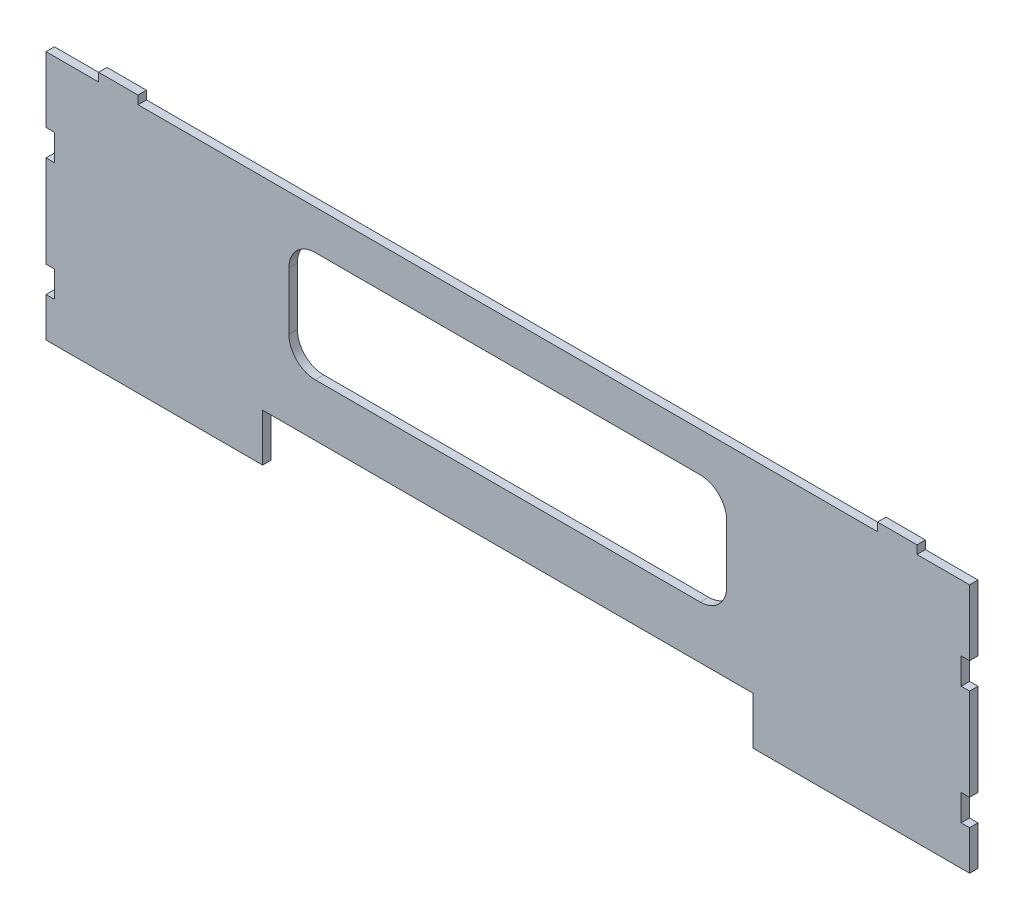
from build123d import *

# Parameters (mm, degrees)
BOSS_EXTRUDE1_DEPTH = 4.064
SKETCH2_W           = 4.064
SKETCH2_H           = 12.7
CUT_EXTRUDE1_DEPTH  = 5.064
CUT_EXTRUDE2_DEPTH  = 5.064


with BuildPart() as part:
    # Sketch1 → Boss-Extrude1 (new body)
    with BuildSketch(Plane.XY):
        Polygon((-118.4275, -120.65), (-118.4275, -97.663), (118.4275, -97.663), (118.4275, -120.65), (223.0755, -120.65), (223.0755, 0), (197.6755, 0), (197.6755, 4.064), (178.6255, 4.064), (178.6255, 0), (-178.6255, 0), (-178.6255, 4.064), (-197.6755, 4.064), (-197.6755, 0), (-223.0755, 0), (-223.0755, -120.65), align=None)
    extrude(amount=BOSS_EXTRUDE1_DEPTH)

    # Sketch2 → Cut-Extrude1 (cut, through all)
    with BuildSketch(Plane.XY.offset(4.064)):
        with Locations((-221.0435, -38.1)):
            Rectangle(SKETCH2_W, SKETCH2_H)
        with Locations((-221.0435, -95.25)):
            Rectangle(SKETCH2_W, SKETCH2_H)
        with Locations((221.0435, -95.25)):
            Rectangle(SKETCH2_W, SKETCH2_H)
        with Locations((221.0435, -38.1)):
            Rectangle(SKETCH2_W, SKETCH2_H)
    extrude(amount=-CUT_EXTRUDE1_DEPTH, mode=Mode.SUBTRACT)

    # Sketch3 → Cut-Extrude2 (cut, through all)
    with BuildSketch(Plane.XY.offset(4.064)):
        with BuildLine():
            Line((-93.0275, -19.05), (93.0275, -19.05))
            ThreePointArc((93.0275, -19.05), (102.007756121, -22.769743879), (105.7275, -31.75))
            Line((105.7275, -31.75), (105.7275, -59.563))
            ThreePointArc((105.7275, -59.563), (102.007756121, -68.543256121), (93.0275, -72.263))
            Line((93.0275, -72.263), (-93.0275, -72.263))
            ThreePointArc((-93.0275, -72.263), (-102.007756121, -68.543256121), (-105.7275, -59.563))
            Line((-105.7275, -59.563), (-105.7275, -31.75))
            ThreePointArc((-105.7275, -31.75), (-102.007756121, -22.769743879), (-93.0275, -19.05))
        make_face()
    extrude(amount=-CUT_EXTRUDE2_DEPTH, mode=Mode.SUBTRACT)


solid = part.part
